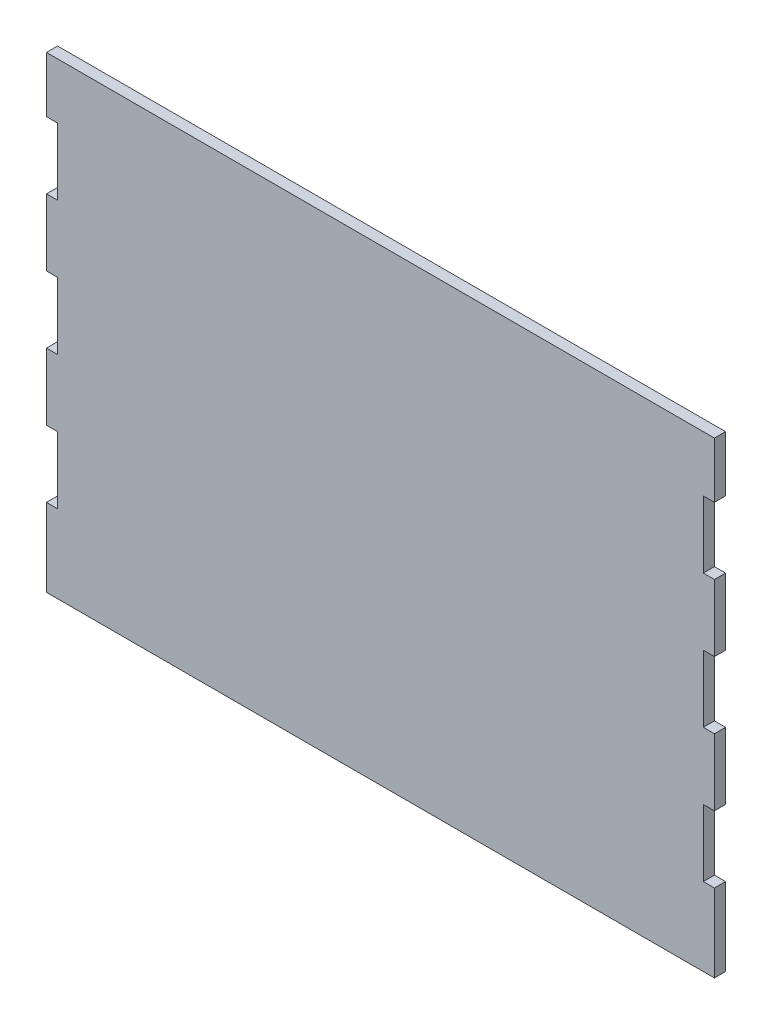
from build123d import *

# Parameters (mm, degrees)
SKETCH1_W           = 300
SKETCH1_H           = 210
BOSS_EXTRUDE1_DEPTH = 5
SKETCH2_W           = 67.619836516
SKETCH2_H           = 30
SKETCH2_W_2         = 72.619836516
SKETCH2_W_3         = 53.212613818
CUT_EXTRUDE1_DEPTH  = 6


with BuildPart() as part:
    # Sketch1 → Boss-Extrude1 (new body)
    with BuildSketch(Plane.XY):
        Rectangle(SKETCH1_W, SKETCH1_H)
    extrude(amount=BOSS_EXTRUDE1_DEPTH)

    # Sketch2 → Cut-Extrude1 (cut, through all)
    with BuildSketch(Plane(origin=(0, 0, 0), x_dir=(-1, 0, 0), z_dir=(0, 0, -1))):
        with Locations((-178.809918258, 65)):
            Rectangle(SKETCH2_W, SKETCH2_H)
        with Locations((-181.309918258, 5)):
            Rectangle(SKETCH2_W_2, SKETCH2_H)
        with Locations((-181.309918258, -55)):
            Rectangle(SKETCH2_W_2, SKETCH2_H)
        with Locations((171.606306909, 65)):
            Rectangle(SKETCH2_W_3, SKETCH2_H)
        with Locations((181.309918258, 5)):
            Rectangle(SKETCH2_W_2, SKETCH2_H)
        with Locations((181.309918258, -55)):
            Rectangle(SKETCH2_W_2, SKETCH2_H)
    extrude(amount=-CUT_EXTRUDE1_DEPTH, mode=Mode.SUBTRACT)


solid = part.part
